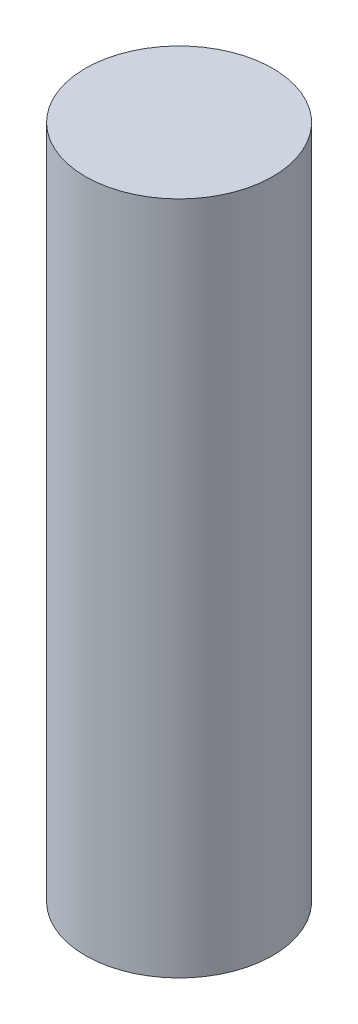
from build123d import *

# Parameters (mm, degrees)
SKETCH1_R           = 2.5
BOSS_EXTRUDE1_DEPTH = 18


with BuildPart() as part:
    # Sketch1 → Boss-Extrude1 (new body)
    with BuildSketch(Plane(origin=(0, 0, 0), x_dir=(1, 0, 0), z_dir=(0, 1, 0))):
        Circle(SKETCH1_R)
    extrude(amount=BOSS_EXTRUDE1_DEPTH)


solid = part.part
